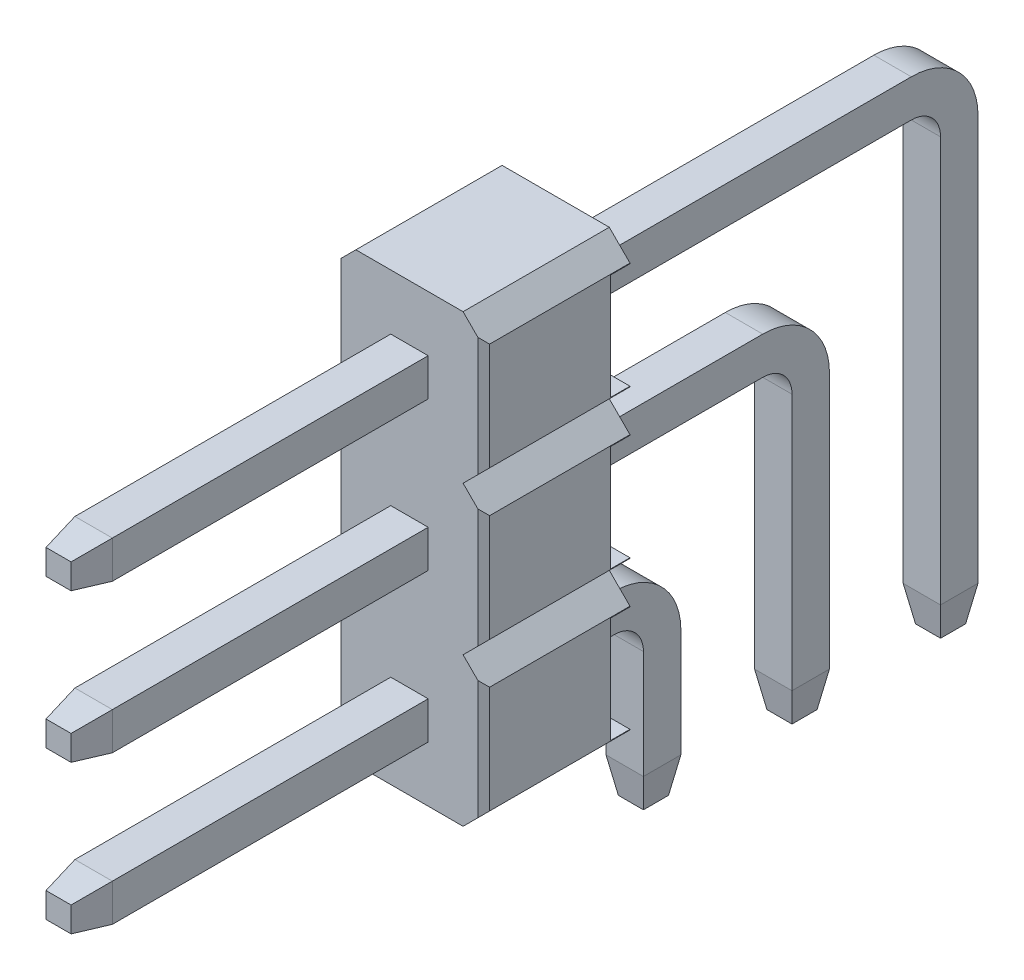
from build123d import *

# Parameters (mm, degrees)
BOSS_EXTRU_1_DEPTH                      = 1.25
ESQUISSE2_W                             = 0.33
ESQUISSE2_H                             = 1.812893218
ENL_V_MAT_EXTRU_2_DEPTH                 = 3.54
CHANFREIN1_SIZE                         = 0.1
R_P_TITION_LIN_AIRE1_COUNT              = 3
R_P_TITION_LIN_AIRE1_PITCH              = 2.54
CHANFREIN1_OF_R_P_TITION_LIN_AIRE1_SIZE = 0.1
BOSS_EXTRU_2_DEPTH                      = 0.32
CHANFREIN2_SIZE                         = 0.6
CHANFREIN2_SIZE2                        = 0.105796188
CHANFREIN2_PART_2_SIZE                  = 0.6
CHANFREIN2_PART_2_SIZE2                 = 0.105796188
CHANFREIN2_PART_3_SIZE                  = 0.6
CHANFREIN2_PART_3_SIZE2                 = 0.105796188
CHANFREIN2_PART_4_SIZE                  = 0.6
CHANFREIN2_PART_4_SIZE2                 = 0.105796188
CHANFREIN2_PART_5_SIZE                  = 0.6
CHANFREIN2_PART_5_SIZE2                 = 0.105796188
CHANFREIN2_PART_6_SIZE                  = 0.6
CHANFREIN2_PART_6_SIZE2                 = 0.105796188
CHANFREIN2_PART_7_SIZE                  = 0.6
CHANFREIN2_PART_7_SIZE2                 = 0.105796188
CHANFREIN2_PART_8_SIZE                  = 0.6
CHANFREIN2_PART_8_SIZE2                 = 0.105796188
CHANFREIN2_PART_9_SIZE                  = 0.6
CHANFREIN2_PART_9_SIZE2                 = 0.105796188
CHANFREIN2_PART_10_SIZE                 = 0.6
CHANFREIN2_PART_10_SIZE2                = 0.105796188
CHANFREIN2_PART_11_SIZE                 = 0.6
CHANFREIN2_PART_11_SIZE2                = 0.105796188
CHANFREIN2_PART_12_SIZE                 = 0.6
CHANFREIN2_PART_12_SIZE2                = 0.105796188
CHANFREIN2_PART_13_SIZE                 = 0.6
CHANFREIN2_PART_13_SIZE2                = 0.105796188
CHANFREIN2_PART_14_SIZE                 = 0.6
CHANFREIN2_PART_14_SIZE2                = 0.105796188
CHANFREIN2_PART_15_SIZE                 = 0.6
CHANFREIN2_PART_15_SIZE2                = 0.105796188
CHANFREIN2_PART_16_SIZE                 = 0.6
CHANFREIN2_PART_16_SIZE2                = 0.105796188
CHANFREIN2_PART_17_SIZE                 = 0.6
CHANFREIN2_PART_17_SIZE2                = 0.105796188
CHANFREIN2_PART_18_SIZE                 = 0.6
CHANFREIN2_PART_18_SIZE2                = 0.105796188
CHANFREIN2_PART_19_SIZE                 = 0.6
CHANFREIN2_PART_19_SIZE2                = 0.105796188
CHANFREIN2_PART_20_SIZE                 = 0.6
CHANFREIN2_PART_20_SIZE2                = 0.105796188
CHANFREIN2_PART_21_SIZE                 = 0.6
CHANFREIN2_PART_21_SIZE2                = 0.105796188
CHANFREIN2_PART_22_SIZE                 = 0.6
CHANFREIN2_PART_22_SIZE2                = 0.105796188
CHANFREIN2_PART_23_SIZE                 = 0.6
CHANFREIN2_PART_23_SIZE2                = 0.105796188
CHANFREIN2_PART_24_SIZE                 = 0.6
CHANFREIN2_PART_24_SIZE2                = 0.105796188


with BuildPart() as part:
    # Esquisse1 → Boss.-Extru.1 (new body, symmetric)
    with BuildSketch(Plane.XY):
        Polygon((-0.916446609, 1.27), (0.916446609, 1.27), (1.27, 0.916446609), (1.27, -0.916446609), (0.916446609, -1.27), (-0.916446609, -1.27), (-1.27, -0.916446609), (-1.27, 0.916446609), align=None)
    boss_extru_1 = extrude(amount=BOSS_EXTRU_1_DEPTH, both=True)

    # Esquisse2 → Enlèv. mat.-Extru.2 (cut, through all)
    with BuildSketch(Plane(origin=(1.27, 0, 0), x_dir=(0, 0, -1), z_dir=(1, 0, 0))):
        with Locations((1.085, 0)):
            Rectangle(ESQUISSE2_W, ESQUISSE2_H)
    enl_v_mat_extru_2 = extrude(amount=-ENL_V_MAT_EXTRU_2_DEPTH, mode=Mode.SUBTRACT)

    # Chanfrein1
    chanfrein1_edges = [part.edges().sort_by_distance(p)[0] for p in [
        (1.27, 0, 1.25),
        (-1.27, 0, 1.25),
    ]]
    chamfer(chanfrein1_edges, length=CHANFREIN1_SIZE)

    # Répétition linéaire1: Boss.-Extru.1, Enlèv. mat.-Extru.2 ×3
    with Locations(*[(0, i * R_P_TITION_LIN_AIRE1_PITCH, 0) for i in range(1, R_P_TITION_LIN_AIRE1_COUNT)]):
        add(boss_extru_1)
        add(enl_v_mat_extru_2, mode=Mode.SUBTRACT)

    # Chanfrein1 of Répétition linéaire1
    chanfrein1_of_r_p_tition_lin_aire1_edges = [part.edges().sort_by_distance(p)[0] for p in [
        (1.27, 2.54, 1.25),
        (-1.27, 2.54, 1.25),
        (1.27, 5.08, 1.25),
        (-1.27, 5.08, 1.25),
    ]]
    chamfer(chanfrein1_of_r_p_tition_lin_aire1_edges, length=CHANFREIN1_OF_R_P_TITION_LIN_AIRE1_SIZE)

    # Esquisse3 → Boss.-Extru.2 (add, symmetric)
    with BuildSketch(Plane(origin=(0, 0, 0), x_dir=(0, 0, -1), z_dir=(1, 0, 0))):
        with BuildLine():
            Line((-7.25, -0.32), (-7.25, 0.32))
            Line((-7.25, 0.32), (1.93, 0.32))
            ThreePointArc((1.93, 0.32), (2.736101731, -0.013898269), (3.07, -0.82))
            Line((3.07, -0.82), (3.07, -3.27))
            Line((3.07, -3.27), (2.43, -3.27))
            Line((2.43, -3.27), (2.43, -0.82))
            ThreePointArc((2.43, -0.82), (2.283553391, -0.466446609), (1.93, -0.32))
            Line((1.93, -0.32), (-7.25, -0.32))
        make_face()
        with BuildLine():
            Line((-7.25, 2.86), (4.47, 2.86))
            ThreePointArc((4.47, 2.86), (5.276101731, 2.526101731), (5.61, 1.72))
            Line((5.61, 1.72), (5.61, -3.27))
            Line((5.61, -3.27), (4.97, -3.27))
            Line((4.97, -3.27), (4.97, 1.72))
            ThreePointArc((4.97, 1.72), (4.823553391, 2.073553391), (4.47, 2.22))
            Line((4.47, 2.22), (-7.25, 2.22))
            Line((-7.25, 2.22), (-7.25, 2.86))
        make_face()
        with BuildLine():
            Line((-7.25, 5.4), (7.01, 5.4))
            ThreePointArc((7.01, 5.4), (7.816101731, 5.066101731), (8.15, 4.26))
            Line((8.15, 4.26), (8.15, -3.27))
            Line((8.15, -3.27), (7.51, -3.27))
            Line((7.51, -3.27), (7.51, 4.26))
            ThreePointArc((7.51, 4.26), (7.363553391, 4.613553391), (7.01, 4.76))
            Line((7.01, 4.76), (-7.25, 4.76))
            Line((-7.25, 4.76), (-7.25, 5.4))
        make_face()
    extrude(amount=BOSS_EXTRU_2_DEPTH, both=True)

    # Chanfrein2
    chanfrein2_edges = [part.edges().sort_by_distance(p)[0] for p in [
        (0.32, -3.27, -2.75),
    ]]
    chanfrein2_side = [part.faces().sort_by_distance(p)[0] for p in [
        (0.32, -0.436857253, -2.313142747),
    ]]
    chamfer(chanfrein2_edges, length=CHANFREIN2_SIZE, length2=CHANFREIN2_SIZE2, reference=chanfrein2_side[0])

    # Chanfrein2 part 2
    chanfrein2_part_2_edges = [part.edges().sort_by_distance(p)[0] for p in [
        (0, -0.32, 7.25),
    ]]
    chanfrein2_part_2_side = [part.faces().sort_by_distance(p)[0] for p in [
        (0, -0.32, 4.25),
    ]]
    chamfer(chanfrein2_part_2_edges, length=CHANFREIN2_PART_2_SIZE, length2=CHANFREIN2_PART_2_SIZE2, reference=chanfrein2_part_2_side[0])

    # Chanfrein2 part 3
    chanfrein2_part_3_edges = [part.edges().sort_by_distance(p)[0] for p in [
        (-0.32, -3.27, -2.75),
    ]]
    chanfrein2_part_3_side = [part.faces().sort_by_distance(p)[0] for p in [
        (-0.32, -0.436857253, -2.313142747),
    ]]
    chamfer(chanfrein2_part_3_edges, length=CHANFREIN2_PART_3_SIZE, length2=CHANFREIN2_PART_3_SIZE2, reference=chanfrein2_part_3_side[0])

    # Chanfrein2 part 4
    chanfrein2_part_4_edges = [part.edges().sort_by_distance(p)[0] for p in [
        (0, -3.27, -2.43),
    ]]
    chanfrein2_part_4_side = [part.faces().sort_by_distance(p)[0] for p in [
        (0, -2.045, -2.43),
    ]]
    chamfer(chanfrein2_part_4_edges, length=CHANFREIN2_PART_4_SIZE, length2=CHANFREIN2_PART_4_SIZE2, reference=chanfrein2_part_4_side[0])

    # Chanfrein2 part 5
    chanfrein2_part_5_edges = [part.edges().sort_by_distance(p)[0] for p in [
        (0, -3.27, -3.07),
    ]]
    chanfrein2_part_5_side = [part.faces().sort_by_distance(p)[0] for p in [
        (0, -2.045, -3.07),
    ]]
    chamfer(chanfrein2_part_5_edges, length=CHANFREIN2_PART_5_SIZE, length2=CHANFREIN2_PART_5_SIZE2, reference=chanfrein2_part_5_side[0])

    # Chanfrein2 part 6
    chanfrein2_part_6_edges = [part.edges().sort_by_distance(p)[0] for p in [
        (-0.32, 0, 7.25),
    ]]
    chanfrein2_part_6_side = [part.faces().sort_by_distance(p)[0] for p in [
        (-0.32, 0, 4.25),
    ]]
    chamfer(chanfrein2_part_6_edges, length=CHANFREIN2_PART_6_SIZE, length2=CHANFREIN2_PART_6_SIZE2, reference=chanfrein2_part_6_side[0])

    # Chanfrein2 part 7
    chanfrein2_part_7_edges = [part.edges().sort_by_distance(p)[0] for p in [
        (0, 0.32, 7.25),
    ]]
    chanfrein2_part_7_side = [part.faces().sort_by_distance(p)[0] for p in [
        (0, 0.32, 4.25),
    ]]
    chamfer(chanfrein2_part_7_edges, length=CHANFREIN2_PART_7_SIZE, length2=CHANFREIN2_PART_7_SIZE2, reference=chanfrein2_part_7_side[0])

    # Chanfrein2 part 8
    chanfrein2_part_8_edges = [part.edges().sort_by_distance(p)[0] for p in [
        (0.32, 0, 7.25),
    ]]
    chanfrein2_part_8_side = [part.faces().sort_by_distance(p)[0] for p in [
        (0.32, 0, 4.25),
    ]]
    chamfer(chanfrein2_part_8_edges, length=CHANFREIN2_PART_8_SIZE, length2=CHANFREIN2_PART_8_SIZE2, reference=chanfrein2_part_8_side[0])

    # Chanfrein2 part 9
    chanfrein2_part_9_edges = [part.edges().sort_by_distance(p)[0] for p in [
        (0.32, -3.27, -5.29),
    ]]
    chanfrein2_part_9_side = [part.faces().sort_by_distance(p)[0] for p in [
        (0.32, 2.54, -0.997183547),
    ]]
    chamfer(chanfrein2_part_9_edges, length=CHANFREIN2_PART_9_SIZE, length2=CHANFREIN2_PART_9_SIZE2, reference=chanfrein2_part_9_side[0])

    # Chanfrein2 part 10
    chanfrein2_part_10_edges = [part.edges().sort_by_distance(p)[0] for p in [
        (0, 2.22, 7.25),
    ]]
    chanfrein2_part_10_side = [part.faces().sort_by_distance(p)[0] for p in [
        (0, 2.22, 4.25),
    ]]
    chamfer(chanfrein2_part_10_edges, length=CHANFREIN2_PART_10_SIZE, length2=CHANFREIN2_PART_10_SIZE2, reference=chanfrein2_part_10_side[0])

    # Chanfrein2 part 11
    chanfrein2_part_11_edges = [part.edges().sort_by_distance(p)[0] for p in [
        (-0.32, -3.27, -5.29),
    ]]
    chanfrein2_part_11_side = [part.faces().sort_by_distance(p)[0] for p in [
        (-0.32, 2.54, -0.997183547),
    ]]
    chamfer(chanfrein2_part_11_edges, length=CHANFREIN2_PART_11_SIZE, length2=CHANFREIN2_PART_11_SIZE2, reference=chanfrein2_part_11_side[0])

    # Chanfrein2 part 12
    chanfrein2_part_12_edges = [part.edges().sort_by_distance(p)[0] for p in [
        (0, -3.27, -4.97),
    ]]
    chanfrein2_part_12_side = [part.faces().sort_by_distance(p)[0] for p in [
        (0, -0.775, -4.97),
    ]]
    chamfer(chanfrein2_part_12_edges, length=CHANFREIN2_PART_12_SIZE, length2=CHANFREIN2_PART_12_SIZE2, reference=chanfrein2_part_12_side[0])

    # Chanfrein2 part 13
    chanfrein2_part_13_edges = [part.edges().sort_by_distance(p)[0] for p in [
        (0, -3.27, -5.61),
    ]]
    chanfrein2_part_13_side = [part.faces().sort_by_distance(p)[0] for p in [
        (0, -0.775, -5.61),
    ]]
    chamfer(chanfrein2_part_13_edges, length=CHANFREIN2_PART_13_SIZE, length2=CHANFREIN2_PART_13_SIZE2, reference=chanfrein2_part_13_side[0])

    # Chanfrein2 part 14
    chanfrein2_part_14_edges = [part.edges().sort_by_distance(p)[0] for p in [
        (-0.32, 2.54, 7.25),
    ]]
    chanfrein2_part_14_side = [part.faces().sort_by_distance(p)[0] for p in [
        (-0.32, 2.54, 4.25),
    ]]
    chamfer(chanfrein2_part_14_edges, length=CHANFREIN2_PART_14_SIZE, length2=CHANFREIN2_PART_14_SIZE2, reference=chanfrein2_part_14_side[0])

    # Chanfrein2 part 15
    chanfrein2_part_15_edges = [part.edges().sort_by_distance(p)[0] for p in [
        (0, 2.86, 7.25),
    ]]
    chanfrein2_part_15_side = [part.faces().sort_by_distance(p)[0] for p in [
        (0, 2.86, 4.25),
    ]]
    chamfer(chanfrein2_part_15_edges, length=CHANFREIN2_PART_15_SIZE, length2=CHANFREIN2_PART_15_SIZE2, reference=chanfrein2_part_15_side[0])

    # Chanfrein2 part 16
    chanfrein2_part_16_edges = [part.edges().sort_by_distance(p)[0] for p in [
        (0.32, 2.54, 7.25),
    ]]
    chanfrein2_part_16_side = [part.faces().sort_by_distance(p)[0] for p in [
        (0.32, 2.54, 4.25),
    ]]
    chamfer(chanfrein2_part_16_edges, length=CHANFREIN2_PART_16_SIZE, length2=CHANFREIN2_PART_16_SIZE2, reference=chanfrein2_part_16_side[0])

    # Chanfrein2 part 17
    chanfrein2_part_17_edges = [part.edges().sort_by_distance(p)[0] for p in [
        (0.32, -3.27, -7.83),
    ]]
    chanfrein2_part_17_side = [part.faces().sort_by_distance(p)[0] for p in [
        (0.32, 4.693378762, -7.443378762),
    ]]
    chamfer(chanfrein2_part_17_edges, length=CHANFREIN2_PART_17_SIZE, length2=CHANFREIN2_PART_17_SIZE2, reference=chanfrein2_part_17_side[0])

    # Chanfrein2 part 18
    chanfrein2_part_18_edges = [part.edges().sort_by_distance(p)[0] for p in [
        (0, 4.76, 7.25),
    ]]
    chanfrein2_part_18_side = [part.faces().sort_by_distance(p)[0] for p in [
        (0, 4.76, 4.25),
    ]]
    chamfer(chanfrein2_part_18_edges, length=CHANFREIN2_PART_18_SIZE, length2=CHANFREIN2_PART_18_SIZE2, reference=chanfrein2_part_18_side[0])

    # Chanfrein2 part 19
    chanfrein2_part_19_edges = [part.edges().sort_by_distance(p)[0] for p in [
        (-0.32, -3.27, -7.83),
    ]]
    chanfrein2_part_19_side = [part.faces().sort_by_distance(p)[0] for p in [
        (-0.32, 4.693378762, -7.443378762),
    ]]
    chamfer(chanfrein2_part_19_edges, length=CHANFREIN2_PART_19_SIZE, length2=CHANFREIN2_PART_19_SIZE2, reference=chanfrein2_part_19_side[0])

    # Chanfrein2 part 20
    chanfrein2_part_20_edges = [part.edges().sort_by_distance(p)[0] for p in [
        (0, -3.27, -7.51),
    ]]
    chanfrein2_part_20_side = [part.faces().sort_by_distance(p)[0] for p in [
        (0, 0.495, -7.51),
    ]]
    chamfer(chanfrein2_part_20_edges, length=CHANFREIN2_PART_20_SIZE, length2=CHANFREIN2_PART_20_SIZE2, reference=chanfrein2_part_20_side[0])

    # Chanfrein2 part 21
    chanfrein2_part_21_edges = [part.edges().sort_by_distance(p)[0] for p in [
        (0, -3.27, -8.15),
    ]]
    chanfrein2_part_21_side = [part.faces().sort_by_distance(p)[0] for p in [
        (0, 0.495, -8.15),
    ]]
    chamfer(chanfrein2_part_21_edges, length=CHANFREIN2_PART_21_SIZE, length2=CHANFREIN2_PART_21_SIZE2, reference=chanfrein2_part_21_side[0])

    # Chanfrein2 part 22
    chanfrein2_part_22_edges = [part.edges().sort_by_distance(p)[0] for p in [
        (-0.32, 5.08, 7.25),
    ]]
    chanfrein2_part_22_side = [part.faces().sort_by_distance(p)[0] for p in [
        (-0.32, 5.08, 4.25),
    ]]
    chamfer(chanfrein2_part_22_edges, length=CHANFREIN2_PART_22_SIZE, length2=CHANFREIN2_PART_22_SIZE2, reference=chanfrein2_part_22_side[0])

    # Chanfrein2 part 23
    chanfrein2_part_23_edges = [part.edges().sort_by_distance(p)[0] for p in [
        (0, 5.4, 7.25),
    ]]
    chanfrein2_part_23_side = [part.faces().sort_by_distance(p)[0] for p in [
        (0, 5.4, 4.25),
    ]]
    chamfer(chanfrein2_part_23_edges, length=CHANFREIN2_PART_23_SIZE, length2=CHANFREIN2_PART_23_SIZE2, reference=chanfrein2_part_23_side[0])

    # Chanfrein2 part 24
    chanfrein2_part_24_edges = [part.edges().sort_by_distance(p)[0] for p in [
        (0.32, 5.08, 7.25),
    ]]
    chanfrein2_part_24_side = [part.faces().sort_by_distance(p)[0] for p in [
        (0.32, 5.08, 4.25),
    ]]
    chamfer(chanfrein2_part_24_edges, length=CHANFREIN2_PART_24_SIZE, length2=CHANFREIN2_PART_24_SIZE2, reference=chanfrein2_part_24_side[0])


solid = part.part
